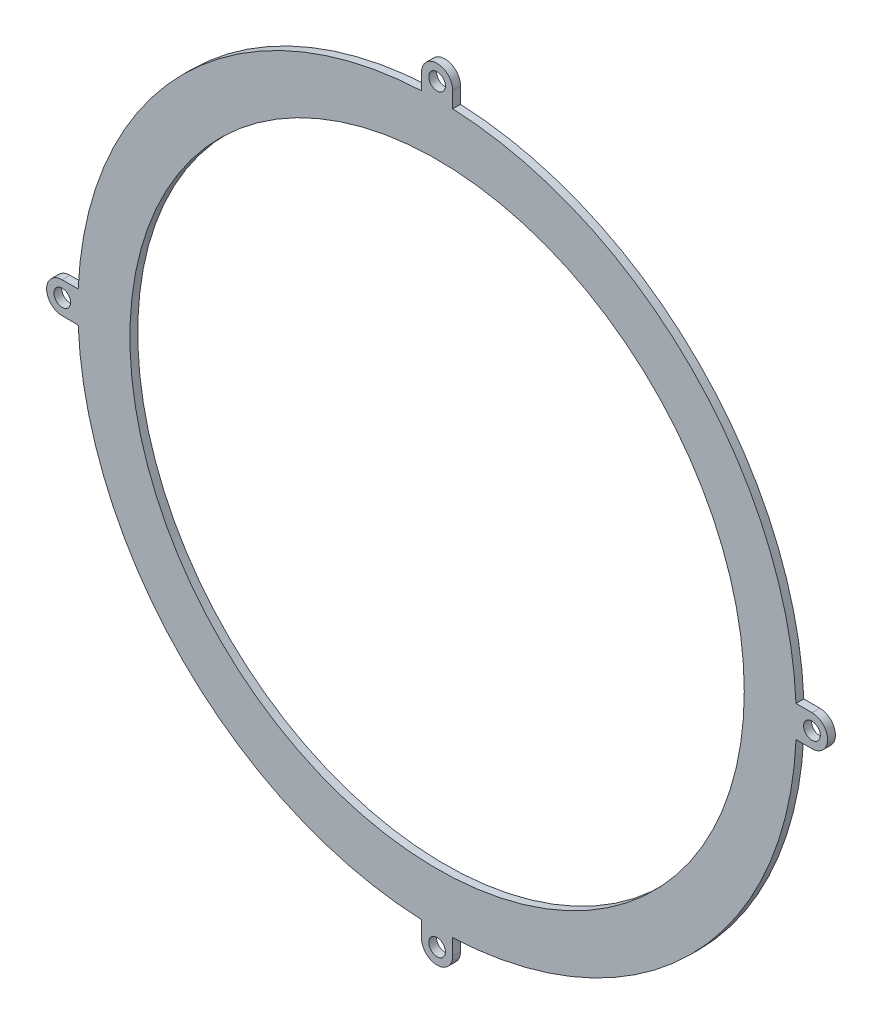
from build123d import *

# Parameters (mm, degrees)
SKETCH1_R           = 59
SKETCH1_R_2         = 1.6
BOSS_EXTRUDE1_DEPTH = 1.5


with BuildPart() as part:
    # Sketch1 → Boss-Extrude1 (new body)
    with BuildSketch(Plane.XY):
        with BuildLine():
            Line((68.934751758, -3), (72, -3))
            ThreePointArc((72, -3), (75, 0), (72, 3))
            Line((72, 3), (68.934751758, 3))
            ThreePointArc((68.934751758, 3), (48.790367902, 48.790367902), (3, 68.934751758))
            Line((3, 68.934751758), (3, 72))
            ThreePointArc((3, 72), (0, 75), (-3, 72))
            Line((-3, 72), (-3, 68.934751758))
            ThreePointArc((-3, 68.934751758), (-48.790367902, 48.790367902), (-68.934751758, 3))
            Line((-68.934751758, 3), (-72, 3))
            ThreePointArc((-72, 3), (-75, 0), (-72, -3))
            Line((-72, -3), (-68.934751758, -3))
            ThreePointArc((-68.934751758, -3), (-48.790367902, -48.790367902), (-3, -68.934751758))
            Line((-3, -68.934751758), (-3, -72))
            ThreePointArc((-3, -72), (0, -75), (3, -72))
            Line((3, -72), (3, -68.934751758))
            ThreePointArc((3, -68.934751758), (48.790367902, -48.790367902), (68.934751758, -3))
        make_face()
        Circle(SKETCH1_R, mode=Mode.SUBTRACT)
        with Locations((0, 72)):
            Circle(SKETCH1_R_2, mode=Mode.SUBTRACT)
        with Locations((72, 0)):
            Circle(SKETCH1_R_2, mode=Mode.SUBTRACT)
        with Locations((0, -72)):
            Circle(SKETCH1_R_2, mode=Mode.SUBTRACT)
        with Locations((-72, 0)):
            Circle(SKETCH1_R_2, mode=Mode.SUBTRACT)
    extrude(amount=BOSS_EXTRUDE1_DEPTH)


solid = part.part
